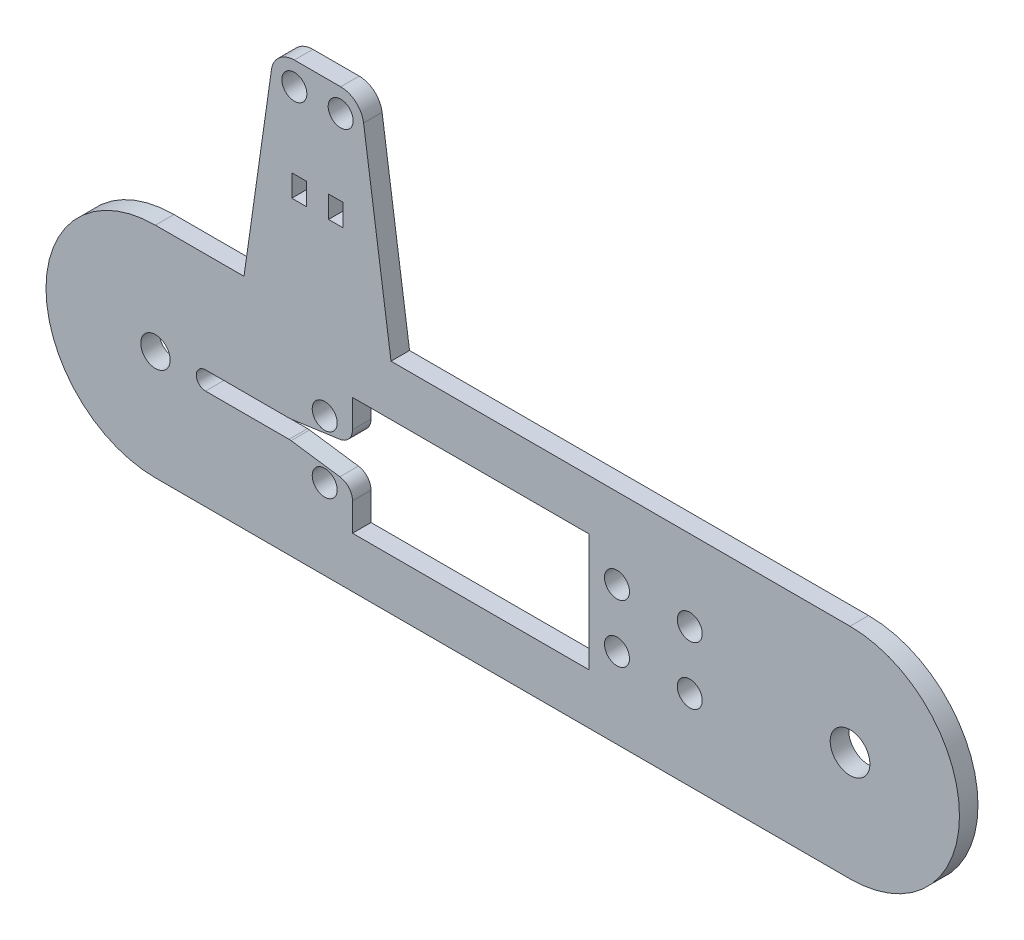
from build123d import *

# Parameters (mm, degrees)
SKETCH1_R           = 3.429
SKETCH1_R_2         = 2.54
BOSS_EXTRUDE1_DEPTH = 3.2004
SKETCH5_R           = 2.159
SKETCH5_W           = 40.894
SKETCH5_H           = 20.32
CUT_EXTRUDE3_DEPTH  = 4.2004
CUT_EXTRUDE4_DEPTH  = 3.2004
CUT_EXTRUDE5_DEPTH  = 3.2004
SKETCH9_R           = 2.159
SKETCH9_W           = 2.54
SKETCH9_H           = 3.81
BOSS_EXTRUDE2_DEPTH = 3.2004
FILLET1_R           = 2.54


with BuildPart() as part:
    # Sketch1 → Boss-Extrude1 (new body)
    with BuildSketch(Plane.XY):
        with BuildLine():
            Line((120.015, 37.81552), (0, 37.81552))
            ThreePointArc((0, 37.81552), (-18.90776, 18.90776), (0, 0))
            Line((0, 0), (120.015, 0))
            ThreePointArc((120.015, 0), (138.92276, 18.90776), (120.015, 37.81552))
        make_face()
        with Locations((120.015, 18.90776)):
            Circle(SKETCH1_R, mode=Mode.SUBTRACT)
        with Locations((0, 18.90776)):
            Circle(SKETCH1_R_2, mode=Mode.SUBTRACT)
    extrude(amount=BOSS_EXTRUDE1_DEPTH)

    # Sketch5 → Cut-Extrude3 (cut, through all)
    with BuildSketch(Plane(origin=(0, 0, 0), x_dir=(-1, 0, 0), z_dir=(0, 0, -1))):
        with Locations((-79.746999972, 23.90776)):
            Circle(SKETCH5_R)
        with Locations((-29.246999972, 13.90776)):
            Circle(SKETCH5_R)
        with Locations((-29.246999972, 23.90776)):
            Circle(SKETCH5_R)
        with Locations((-79.746999972, 13.90776)):
            Circle(SKETCH5_R)
        with Locations((-92.322240346, 23.90776)):
            Circle(SKETCH5_R)
        with Locations((-92.322240346, 13.90776)):
            Circle(SKETCH5_R)
        with Locations((-54.496999972, 18.90776)):
            Rectangle(SKETCH5_W, SKETCH5_H)
    extrude(amount=-CUT_EXTRUDE3_DEPTH, mode=Mode.SUBTRACT)

    # Sketch6 → Cut-Extrude4 (cut)
    with BuildSketch(Plane.XY.offset(3.2004)):
        with BuildLine():
            Line((8.649999972, 20.49526), (25.159999972, 20.49526))
            ThreePointArc((25.159999972, 20.49526), (26.747499972, 18.90776), (25.159999972, 17.32026))
            Line((25.159999972, 17.32026), (8.649999972, 17.32026))
            ThreePointArc((8.649999972, 17.32026), (7.062499972, 18.90776), (8.649999972, 20.49526))
        make_face()
    extrude(amount=-CUT_EXTRUDE4_DEPTH, mode=Mode.SUBTRACT)

    # Sketch8 → Cut-Extrude5 (cut)
    with BuildSketch(Plane.XY.offset(3.2004)):
        Polygon((34.049999972, 15.79626), (34.049999972, 22.01926), (23.264769203, 20.49526), (23.264769203, 17.32026), align=None)
    extrude(amount=-CUT_EXTRUDE5_DEPTH, mode=Mode.SUBTRACT)

    # Sketch9 → Boss-Extrude2 (add)
    with BuildSketch(Plane(origin=(0, 0, 0), x_dir=(-1, 0, 0), z_dir=(0, 0, -1))):
        with BuildLine():
            Line((-40.703500071, 37.81552), (-15.303500071, 37.81552))
            Line((-15.303500071, 37.81552), (-20.042454023, 71.094701578))
            ThreePointArc((-20.042454023, 71.094701578), (-21.381188491, 73.552326238), (-24.003000071, 74.531219996))
            Line((-24.003000071, 74.531219996), (-32.004000071, 74.531219996))
            ThreePointArc((-32.004000071, 74.531219996), (-34.62581165, 73.552326238), (-35.964546118, 71.094701578))
            Line((-35.964546118, 71.094701578), (-40.703500071, 37.81552))
        make_face()
        with Locations((-32.004000071, 70.53072)):
            Circle(SKETCH9_R, mode=Mode.SUBTRACT)
        with Locations((-24.003000071, 70.53072)):
            Circle(SKETCH9_R, mode=Mode.SUBTRACT)
        with Locations((-31.178500071, 55.533488225)):
            Rectangle(SKETCH9_W, SKETCH9_H, mode=Mode.SUBTRACT)
        with Locations((-24.828500071, 55.533488225)):
            Rectangle(SKETCH9_W, SKETCH9_H, mode=Mode.SUBTRACT)
    extrude(amount=-BOSS_EXTRUDE2_DEPTH)

    # Fillet1
    fillet1_edges = [part.edges().sort_by_distance(p)[0] for p in [
        (34.049999972, 22.01926, 1.6002),
        (23.264769203, 20.49526, 1.6002),
        (23.264769203, 17.32026, 1.6002),
        (34.049999972, 15.79626, 1.6002),
    ]]
    fillet(fillet1_edges, radius=FILLET1_R)


solid = part.part
